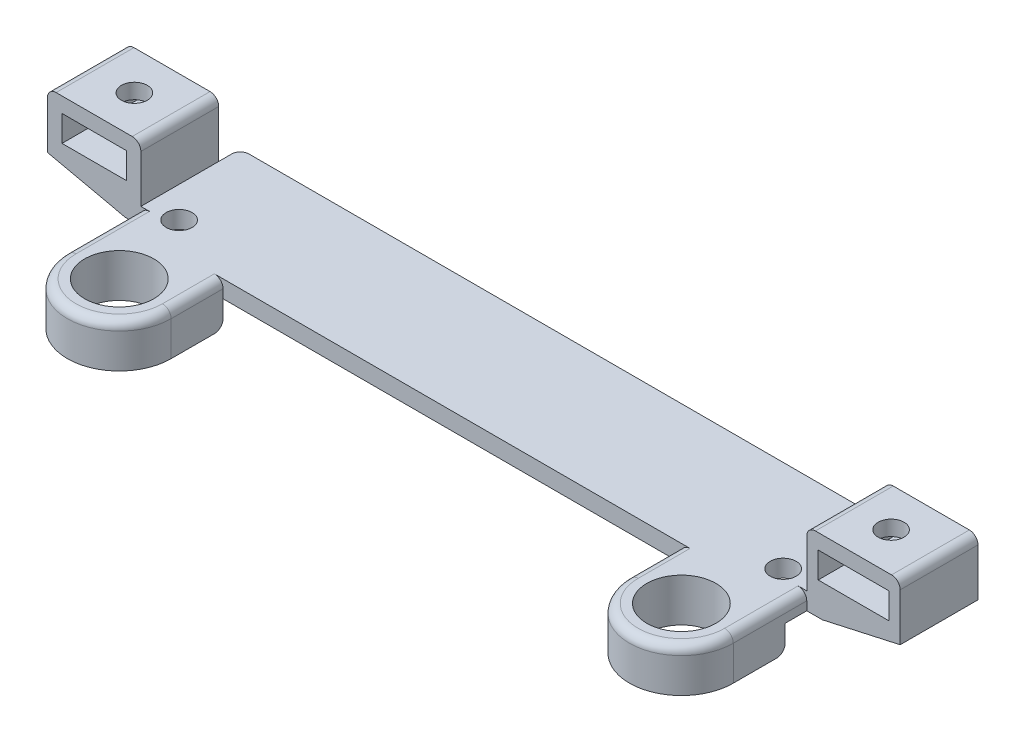
from build123d import *

# Parameters (mm, degrees)
SKETCH1_W           = 77
SKETCH1_H           = 14
BOSS_EXTRUDE1_DEPTH = 2
SKETCH3_W           = 9
SKETCH3_H           = 2
BOSS_EXTRUDE2_DEPTH = 10.8
SKETCH4_W           = 9
SKETCH4_H           = 2
BOSS_EXTRUDE3_DEPTH = 10.8
SKETCH5_W           = 10.8
SKETCH5_H           = 9
BOSS_EXTRUDE4_DEPTH = 6.5
SKETCH6_W           = 8.16
SKETCH6_H           = 3
SKETCH6_W_2         = 7.44
CUT_EXTRUDE1_DEPTH  = 9
SKETCH8_R           = 1.5
CUT_EXTRUDE2_DEPTH  = 8.5
SKETCH10_W          = 9.3
SKETCH10_H          = 6
CUT_EXTRUDE4_DEPTH  = 2
CHAMFER1_SIZE       = 9
CHAMFER1_SIZE2      = 2
BOSS_EXTRUDE5_DEPTH = 5
SKETCH13_R          = 4
CUT_EXTRUDE5_DEPTH  = 5
FILLET3_R           = 1


with BuildPart() as part:
    # Sketch1 → Boss-Extrude1 (new body)
    with BuildSketch(Plane(origin=(0, 0, 0), x_dir=(1, 0, 0), z_dir=(0, 1, 0))):
        with Locations((-53.253755964, -5.729579977)):
            Rectangle(SKETCH1_W, SKETCH1_H)
    extrude(amount=BOSS_EXTRUDE1_DEPTH)

    # Sketch3 → Boss-Extrude2 (add)
    with BuildSketch(Plane.ZY.offset(91.753755964)):
        with Locations((5.729579977, 1)):
            Rectangle(SKETCH3_W, SKETCH3_H)
    extrude(amount=BOSS_EXTRUDE2_DEPTH)

    # Sketch4 → Boss-Extrude3 (add)
    with BuildSketch(Plane(origin=(-14.753755964, 0, 0), x_dir=(0, 0, -1), z_dir=(1, 0, 0))):
        with Locations((-5.729579977, 1)):
            Rectangle(SKETCH4_W, SKETCH4_H)
    extrude(amount=BOSS_EXTRUDE3_DEPTH)

    # Sketch5 → Boss-Extrude4 (add)
    with BuildSketch(Plane(origin=(0, 2, 0), x_dir=(1, 0, 0), z_dir=(0, 1, 0))):
        with Locations((-97.153755964, -5.729579977)):
            Rectangle(SKETCH5_W, SKETCH5_H)
        with Locations((-9.353755964, -5.729579977)):
            Rectangle(SKETCH5_W, SKETCH5_H)
    extrude(amount=BOSS_EXTRUDE4_DEPTH)

    # Sketch6 → Cut-Extrude1 (cut)
    with BuildSketch(Plane.XY.offset(10.229579977)):
        with Locations((-9.353755964, 5.25)):
            Rectangle(SKETCH6_W, SKETCH6_H)
        with Locations((-97.153755964, 5.25)):
            Rectangle(SKETCH6_W_2, SKETCH6_H)
    extrude(amount=-CUT_EXTRUDE1_DEPTH, mode=Mode.SUBTRACT)

    # Sketch8 → Cut-Extrude2 (cut)
    with BuildSketch(Plane(origin=(0, 8.5, 0), x_dir=(1, 0, 0), z_dir=(0, 1, 0))):
        with Locations((-88.178755964, -9.379579977)):
            Circle(SKETCH8_R)
        with Locations((-18.328755964, -9.379579977)):
            Circle(SKETCH8_R)
        with Locations((-97.003755964, -5.729579977)):
            Circle(SKETCH8_R)
        with Locations((-9.503755964, -5.729579977)):
            Circle(SKETCH8_R)
    extrude(amount=-CUT_EXTRUDE2_DEPTH, mode=Mode.SUBTRACT)

    # Sketch10 → Cut-Extrude4 (cut)
    with BuildSketch(Plane(origin=(0, 0, 0), x_dir=(-1, 0, 0), z_dir=(0, -1, 0))):
        with Locations((97.903755964, -5.729579977)):
            Rectangle(SKETCH10_W, SKETCH10_H)
        with Locations((8.603755964, -5.729579977)):
            Rectangle(SKETCH10_W, SKETCH10_H)
    extrude(amount=-CUT_EXTRUDE4_DEPTH, mode=Mode.SUBTRACT)

    # Chamfer1
    chamfer1_edges = [part.edges().sort_by_distance(p)[0] for p in [
        (-102.553755964, 0, 1.979579977),
        (-3.953755964, 0, 9.479579977),
        (-3.953755964, 0, 1.979579977),
        (-102.553755964, 0, 9.479579977),
    ]]
    chamfer1_side = [part.faces().sort_by_distance(p)[0] for p in [
        (-53.253755964, 0, 5.684579251),
    ]]
    chamfer(chamfer1_edges, length=CHAMFER1_SIZE, length2=CHAMFER1_SIZE2, reference=chamfer1_side[0])

    # Sketch12 → Boss-Extrude5 (add)
    with BuildSketch(Plane(origin=(0, 2, 0), x_dir=(1, 0, 0), z_dir=(0, 1, 0))):
        with BuildLine():
            Line((-26.753755964, -12.729579977), (-14.753755964, -12.729579977))
            Line((-14.753755964, -12.729579977), (-14.753755964, -18.729579977))
            ThreePointArc((-14.753755964, -18.729579977), (-20.753755964, -24.729579977), (-26.753755964, -18.729579977))
            Line((-26.753755964, -18.729579977), (-26.753755964, -12.729579977))
        make_face()
        with BuildLine():
            Line((-91.753755964, -12.729579977), (-91.753755964, -18.729579977))
            ThreePointArc((-91.753755964, -18.729579977), (-85.753755964, -24.729579977), (-79.753755964, -18.729579977))
            Line((-79.753755964, -18.729579977), (-79.753755964, -12.729579977))
            Line((-79.753755964, -12.729579977), (-91.753755964, -12.729579977))
        make_face()
    extrude(amount=-BOSS_EXTRUDE5_DEPTH)

    # Sketch13 → Cut-Extrude5 (cut)
    with BuildSketch(Plane(origin=(0, 2, 0), x_dir=(1, 0, 0), z_dir=(0, 1, 0))):
        with Locations((-85.753755964, -18.729579977)):
            Circle(SKETCH13_R)
        with Locations((-20.753755964, -18.729579977)):
            Circle(SKETCH13_R)
    extrude(amount=-CUT_EXTRUDE5_DEPTH, mode=Mode.SUBTRACT)

    # Fillet3
    fillet3_edges = [part.edges().sort_by_distance(p)[0] for p in [
        (-85.753755964, -3, 12.729579977),
        (-85.753755964, 2, 24.729579977),
        (-79.753755964, 2, 15.729579977),
        (-20.753755964, -3, 12.729579977),
        (-20.753755964, 2, 24.729579977),
        (-26.753755964, 2, 15.729579977),
        (-91.753755964, 8.5, 5.729579977),
        (-102.553755964, 8.5, 5.729579977),
        (-14.753755964, 8.5, 5.729579977),
        (-3.953755964, 8.5, 5.729579977),
        (-91.753755964, 1, -1.270420023),
        (-14.753755964, 1, -1.270420023),
    ]]
    fillet(fillet3_edges, radius=FILLET3_R)


solid = part.part
